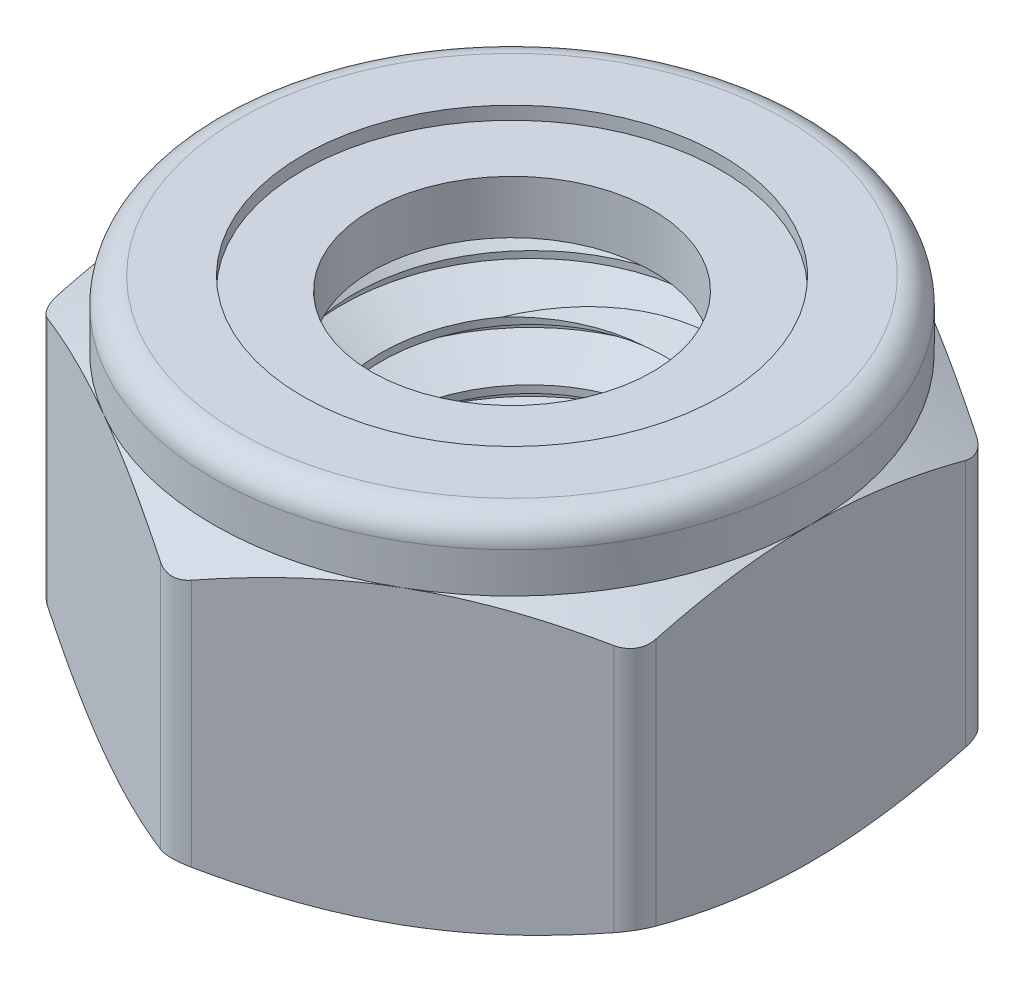
from build123d import *
from build123d.topology import SkipClean

# Parameters (mm, degrees)
BOSS_EXTRUDE1_START = 1.891685
BOSS_EXTRUDE1_DEPTH = 4.891685
FILLET1_R           = 0.514814815
SWEEP1_PITCH        = 1
SWEEP1_HEIGHT       = 6
SWEEP1_RADIUS       = 3
SWEEP1_START_ANGLE  = -90


with BuildPart() as part:
    # Sketch2 → Boss-Extrude1 (new body)
    with BuildSketch(Plane(origin=(0, 0, 0), x_dir=(1, 0, 0), z_dir=(0, 1, 0)).offset(BOSS_EXTRUDE1_START)):
        Polygon((5, 2.886751346), (0, 5.773502692), (-5, 2.886751346), (-5, -2.886751346), (0, -5.773502692), (5, -2.886751346), align=None)
    extrude(amount=-BOSS_EXTRUDE1_DEPTH)

    # Sketch3 → Cut-Revolve1 (revolve, cut)
    with BuildSketch(Plane.XY):
        Polygon((3, 3.046385954), (5.782222222, 1.440069205), (5.782222222, 3.046385954), align=None)
        Polygon((3, -4.154700538), (5.782222222, -2.548383789), (5.782222222, -4.154700538), align=None)
    revolve(axis=Axis((0, 3, 0), (0, -1, 0)), mode=Mode.SUBTRACT)

    # Fillet1
    fillet1_edges = [part.edges().sort_by_distance(p)[0] for p in [
        (-5, -0.554157292, -2.886751346),
        (-5, -0.554157292, 2.886751346),
        (0, -0.554157292, 5.773502692),
        (0, -0.554157292, -5.773502692),
        (5, -0.554157292, -2.886751346),
        (5, -0.554157292, 2.886751346),
    ]]
    fillet(fillet1_edges, radius=FILLET1_R)

    # Sketch5 → Cut-Revolve2 (revolve, cut)
    with BuildSketch(Plane.XY, mode=Mode.PRIVATE) as cut_revolve2_sk:
        Polygon((-3.5, -3), (-3, -2.5), (-3, 1.391685416), (-3.5, 1.891685416), (0, 1.891685416), (0, -3), align=None)
    revolve(cut_revolve2_sk.sketch.rotate(Axis((0, 3, 0), (0, -1, 0)), 270), axis=Axis((0, 3, 0), (0, -1, 0)), mode=Mode.SUBTRACT)


with BuildPart() as revolve1_tool:
    # Sketch4 → Revolve1 (revolve)
    with BuildSketch(Plane.XY):
        with BuildLine():
            Line((-3.5, 3), (-4.5625, 3))
            ThreePointArc((-4.5625, 3), (-4.871859217, 2.871859217), (-5, 2.5625))
            Line((-5, 2.5625), (-5, 1.891685416))
            Line((-5, 1.891685416), (-4.78125, 1.891685416))
            Line((-4.78125, 1.891685416), (-4.78125, 2.5625))
            ThreePointArc((-4.78125, 2.5625), (-4.717179608, 2.717179608), (-4.5625, 2.78125))
            Line((-4.5625, 2.78125), (-3.5, 2.78125))
            Line((-3.5, 2.78125), (-3.5, 3))
        make_face()
    revolve(axis=Axis((0, 3, 0), (0, -1, 0)))


with BuildPart() as part_1:
    add(part.part)


with BuildPart() as part_2:
    # Revolve1: joined with revolve1_tool
    add(part_1.part.fuse(revolve1_tool.part, tol=0.00001))

    # Sweep1: sweep along a helix
    with BuildLine() as sweep1_path:
        add(Helix(SWEEP1_PITCH, SWEEP1_HEIGHT, SWEEP1_RADIUS, center=(0, -3, 0), direction=(0, 1, 0), lefthand=True, mode=Mode.PRIVATE).rotate(Axis((0, -3, 0), (0, 1, 0)), SWEEP1_START_ANGLE))
    # Sketch8 → Sweep1 (sweep)
    with BuildSketch(Plane.XY):
        Polygon((-3.054126588, -2.96875), (-3.054126588, -3.90625), (-2.350480947, -3.5), (-2.350480947, -3.375), align=None)
    sweep(path=sweep1_path.line, is_frenet=True)

    # Sketch9 → Cut-Revolve3 (revolve, cut)
    with SkipClean():  # the faces are left unmerged after this step: merging them gives an invalid solid
        with BuildSketch(Plane.XY, mode=Mode.PRIVATE) as cut_revolve3_sk:
            Polygon((-3.5, 3.21875), (-3.5, 1.891685416), (-2.242227772, 0.633913187), (-2.242227772, 3.21875), align=None)
            Polygon((-2.242227772, -1.742227772), (-3.5, -3), (-3.5, -3.9375), (-2.242227772, -3.9375), align=None)
        revolve(cut_revolve3_sk.sketch.rotate(Axis((0, 3, 0), (0, -1, 0)), 134.999973748), axis=Axis((0, 3, 0), (0, -1, 0)), mode=Mode.SUBTRACT)


with BuildPart() as body_2:
    # Sketch6 → Revolve2 (revolve)
    with BuildSketch(Plane.XY, mode=Mode.PRIVATE) as revolve2_sk:
        with BuildLine():
            Line((-4.5625, 2.78125), (-2.350480947, 2.78125))
            Line((-2.350480947, 2.78125), (-2.350480947, 1.891685416))
            Line((-2.350480947, 1.891685416), (-4.78125, 1.891685416))
            Line((-4.78125, 1.891685416), (-4.78125, 2.5625))
            ThreePointArc((-4.78125, 2.5625), (-4.717179608, 2.717179608), (-4.5625, 2.78125))
        make_face()
    revolve(revolve2_sk.sketch.rotate(Axis((0, 3, 0), (0, -1, 0)), 270), axis=Axis((0, 3, 0), (0, -1, 0)))


solid = Compound([part_2.part, body_2.part])
